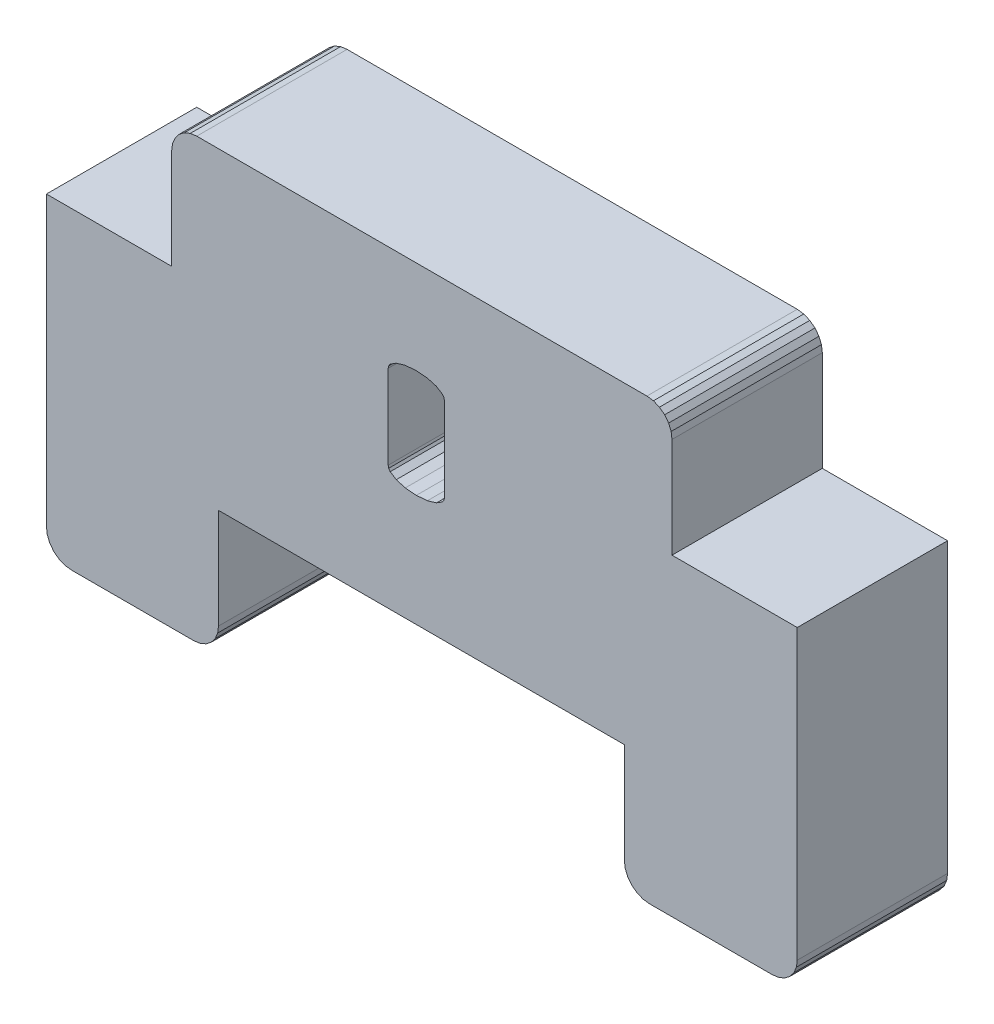
from build123d import *

# Parameters (mm, degrees)
BOSS_EXTRUDE1_DEPTH = 6


with BuildPart() as part:
    # Sketch1 → Boss-Extrude1 (new body)
    with BuildSketch(Plane.XY):
        Polygon((-389.204801714, -169.85436702), (-389.170727541, -169.595547974), (-389.070827118, -169.35436702), (-388.911908496, -169.147260238), (-388.704801714, -168.988341616), (-388.46362076, -168.888441193), (-388.204801714, -168.85436702), (-370.236342553, -168.85436702), (-369.977523508, -168.888441193), (-369.736342553, -168.988341616), (-369.529235771, -169.147260238), (-369.370317149, -169.35436702), (-369.270416726, -169.595547974), (-369.236342553, -169.85436702), (-369.236342553, -173.85436702), (-364.236342553, -173.85436702), (-364.236342553, -185.35436702), (-364.270416726, -185.613186065), (-364.370317149, -185.85436702), (-364.529235771, -186.061473801), (-364.736342553, -186.220392423), (-364.977523508, -186.320292846), (-365.236342553, -186.35436702), (-370.136342553, -186.35436702), (-370.395161598, -186.320292846), (-370.636342553, -186.220392423), (-370.843449334, -186.061473801), (-371.002367956, -185.85436702), (-371.102268379, -185.613186065), (-371.136342553, -185.35436702), (-371.136342553, -181.35436702), (-387.336337557, -181.35436702), (-387.336337557, -185.35436702), (-387.37041173, -185.613186065), (-387.470312153, -185.85436702), (-387.629230775, -186.061473801), (-387.836337557, -186.220392423), (-388.077518511, -186.320292846), (-388.336337557, -186.35436702), (-393.204801714, -186.35436702), (-393.46362076, -186.320292846), (-393.704801714, -186.220392423), (-393.911908496, -186.061473801), (-394.070827118, -185.85436702), (-394.170727541, -185.613186065), (-394.204801714, -185.35436702), (-394.204801714, -173.85436702), (-389.204801714, -173.85436702), align=None)
        Polygon((-380.563744966, -176.407359193), (-380.543648024, -176.503568463), (-380.483357199, -176.59235824), (-380.242193899, -176.747679315), (-379.880830046, -176.853040881), (-379.439840622, -176.888161403), (-378.998851197, -176.853040881), (-378.637487344, -176.747679315), (-378.396324044, -176.59235824), (-378.336033219, -176.503568463), (-378.315936277, -176.407359193), (-378.315936277, -173.060655686), (-378.336033219, -172.964465769), (-378.396324044, -172.875686412), (-378.637487344, -172.720359383), (-378.998851197, -172.614979953), (-379.439840622, -172.579853476), (-379.880830046, -172.614979953), (-380.242193899, -172.720359383), (-380.483357199, -172.875686412), (-380.543648024, -172.964465769), (-380.563744966, -173.060655686), align=None, mode=Mode.SUBTRACT)
    extrude(amount=BOSS_EXTRUDE1_DEPTH)


solid = part.part
